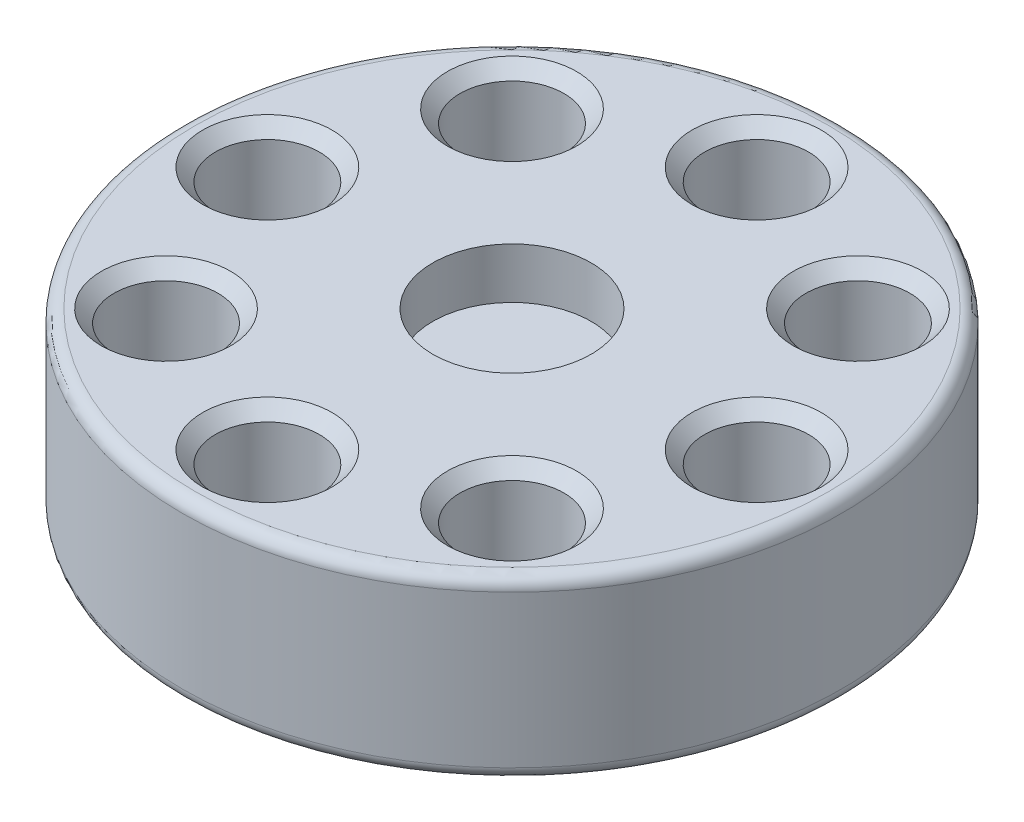
from build123d import *

# Parameters (mm, degrees)
SKETCH1_R           = 26
BOSS_EXTRUDE1_DEPTH = 14
SKETCH2_R           = 6.1
CUT_EXTRUDE2_DEPTH  = 4
CUT_EXTRUDE5_START  = 14
SKETCH1_9_R         = 6.25
CUT_EXTRUDE5_DEPTH  = 4
SKETCH1_13_R        = 4.1
CUT_EXTRUDE6_DEPTH  = 8
CUT_EXTRUDE7_START  = 14
SKETCH1_15_R        = 4.1
CUT_EXTRUDE7_DEPTH  = 15
FILLET3_R           = 1
CHAMFER1_SIZE       = 1


with BuildPart() as part:
    # Sketch1 → Boss-Extrude1 (new body)
    with BuildSketch(Plane(origin=(0, 0, 0), x_dir=(1, 0, 0), z_dir=(0, 1, 0))):
        Circle(SKETCH1_R)
    extrude(amount=BOSS_EXTRUDE1_DEPTH)

    # Sketch2 → Cut-Extrude2 (cut)
    with BuildSketch(Plane.XZ):
        Circle(SKETCH2_R)
    extrude(amount=-CUT_EXTRUDE2_DEPTH, mode=Mode.SUBTRACT)

    # Sketch1_9 → Cut-Extrude5 (cut)
    with BuildSketch(Plane(origin=(0, 0, 0), x_dir=(1, 0, 0), z_dir=(0, 1, 0)).offset(CUT_EXTRUDE5_START)):
        Circle(SKETCH1_9_R)
    extrude(amount=-CUT_EXTRUDE5_DEPTH, mode=Mode.SUBTRACT)

    # Sketch1_13 → Cut-Extrude6 (cut)
    with BuildSketch(Plane(origin=(0, 0, 0), x_dir=(1, 0, 0), z_dir=(0, 1, 0))):
        with Locations((-13.647160877, 13.647160877)):
            Circle(SKETCH1_13_R)
        with Locations((0, 19.3)):
            Circle(SKETCH1_13_R)
        with Locations((13.647160877, 13.647160877)):
            Circle(SKETCH1_13_R)
        with Locations((19.3, 0)):
            Circle(SKETCH1_13_R)
        with Locations((13.647160877, -13.647160877)):
            Circle(SKETCH1_13_R)
        with Locations((0, -19.3)):
            Circle(SKETCH1_13_R)
        with Locations((-13.647160877, -13.647160877)):
            Circle(SKETCH1_13_R)
        with Locations((-19.3, 0)):
            Circle(SKETCH1_13_R)
    extrude(amount=CUT_EXTRUDE6_DEPTH, mode=Mode.SUBTRACT)

    # Sketch1_15 → Cut-Extrude7 (cut, through all)
    with BuildSketch(Plane(origin=(0, 0, 0), x_dir=(1, 0, 0), z_dir=(0, 1, 0)).offset(CUT_EXTRUDE7_START)):
        with Locations((-13.647160877, 13.647160877)):
            Circle(SKETCH1_15_R)
        with Locations((0, 19.3)):
            Circle(SKETCH1_15_R)
        with Locations((13.647160877, 13.647160877)):
            Circle(SKETCH1_15_R)
        with Locations((19.3, 0)):
            Circle(SKETCH1_15_R)
        with Locations((13.647160877, -13.647160877)):
            Circle(SKETCH1_15_R)
        with Locations((0, -19.3)):
            Circle(SKETCH1_15_R)
        with Locations((-13.647160877, -13.647160877)):
            Circle(SKETCH1_15_R)
        with Locations((-19.3, 0)):
            Circle(SKETCH1_15_R)
    extrude(amount=-CUT_EXTRUDE7_DEPTH, mode=Mode.SUBTRACT)

    # Fillet3
    fillet3_edges = [part.edges().sort_by_distance(p)[0] for p in [
        (-26, 0, 0),
        (-26, 14, 0),
    ]]
    fillet(fillet3_edges, radius=FILLET3_R)

    # Chamfer1
    chamfer1_edges = [part.edges().sort_by_distance(p)[0] for p in [
        (-17.747160877, 0, 13.647160877),
        (-23.4, 0, 0),
        (-17.747160877, 0, -13.647160877),
        (-4.1, 0, -19.3),
        (9.547160877, 0, -13.647160877),
        (15.2, 0, 0),
        (9.547160877, 0, 13.647160877),
        (-4.1, 0, 19.3),
        (-17.747160877, 14, 13.647160877),
        (-23.4, 14, 0),
        (-17.747160877, 14, -13.647160877),
        (-4.1, 14, -19.3),
        (-4.1, 14, 19.3),
        (9.547160877, 14, 13.647160877),
        (15.2, 14, 0),
        (9.547160877, 14, -13.647160877),
    ]]
    chamfer(chamfer1_edges, length=CHAMFER1_SIZE)


solid = part.part
